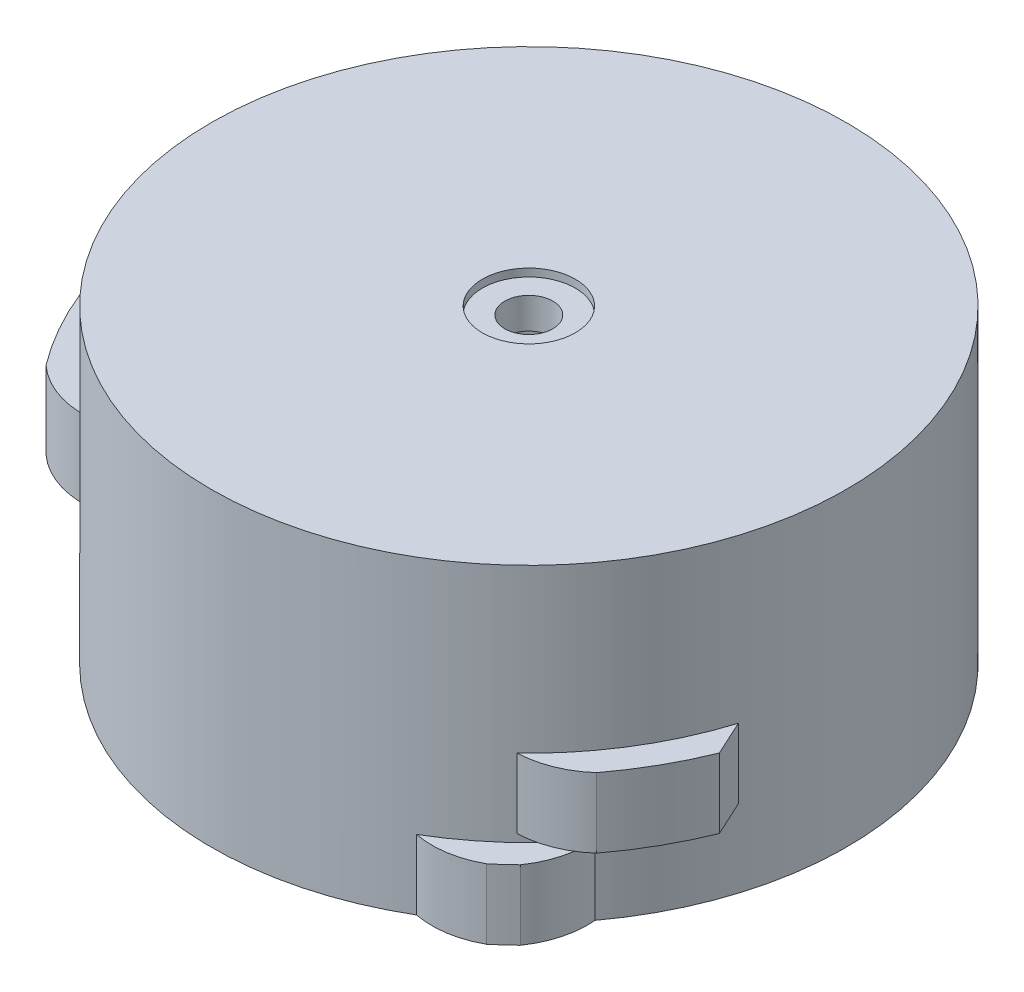
from build123d import *

# Parameters (mm, degrees)
SKETCH2_R           = 41
BOSS_EXTRUDE1_DEPTH = 40
HOME_DEPTH          = 9
END_R_DEPTH         = 9
END_L_DEPTH         = 10
SKETCH8_R           = 35
CUT_EXTRUDE1_DEPTH  = 10
CUT_EXTRUDE3_DEPTH  = 25
CUT_EXTRUDE4_REACH  = 7
SKETCH11_R          = 3.1
SKETCH12_R          = 6
CUT_EXTRUDE5_DEPTH  = 1


with BuildPart() as part:
    # Sketch2 → Boss-Extrude1 (new body)
    with BuildSketch(Plane(origin=(0, 0, 0), x_dir=(1, 0, 0), z_dir=(0, 1, 0))):
        Circle(SKETCH2_R)
    extrude(amount=BOSS_EXTRUDE1_DEPTH)

    # Sketch3 → Home (add)
    with BuildSketch(Plane(origin=(0, 0, 0), x_dir=(1, 0, 0), z_dir=(0, 1, 0))):
        with BuildLine():
            ThreePointArc((28.604048631, -34.088977719), (29.776311983, -33.069944734), (30.912297485, -32.010621115))
            ThreePointArc((30.912297485, -32.010621115), (32.604689255, -28.381998607), (32.953955321, -24.393376738))
            ThreePointArc((32.953955321, -24.393376738), (27.434354861, -30.468937845), (20.815120959, -35.323232291))
            ThreePointArc((20.815120959, -35.323232291), (24.818400986, -35.392804054), (28.604048631, -34.088977719))
        make_face()
    extrude(amount=HOME_DEPTH)

    # Sketch4 → End R (add)
    with BuildSketch(Plane(origin=(0, 10, 0), x_dir=(1, 0, 0), z_dir=(0, 1, 0))):
        with BuildLine():
            Line((41.259681528, -16.669993407), (39.164522306, -12.130135718))
            ThreePointArc((39.164522306, -12.130135718), (34.826898772, -21.635321166), (28.227629104, -29.735516729))
            ThreePointArc((28.227629104, -29.735516729), (32.143955565, -28.90276331), (35.539280197, -26.78076853))
            ThreePointArc((35.539280197, -26.78076853), (38.730828469, -21.912848425), (41.259681528, -16.669993407))
        make_face()
    extrude(amount=END_R_DEPTH)

    # Sketch6 → End L (add)
    with BuildSketch(Plane(origin=(0, 19, 0), x_dir=(1, 0, 0), z_dir=(0, 1, 0))):
        with BuildLine():
            Line((-41.259681528, -16.669993407), (-39.304086987, -11.669993407))
            ThreePointArc((-39.304086987, -11.669993407), (-34.902749486, -21.512742231), (-28.087672455, -29.867752779))
            ThreePointArc((-28.087672455, -29.867752779), (-32.085635632, -28.981220402), (-35.539280197, -26.78076853))
            ThreePointArc((-35.539280197, -26.78076853), (-38.730828469, -21.912848425), (-41.259681528, -16.669993407))
        make_face()
    extrude(amount=END_L_DEPTH)

    # Sketch8 → Cut-Extrude1 (cut)
    with BuildSketch(Plane.XZ):
        Circle(SKETCH8_R)
    extrude(amount=-CUT_EXTRUDE1_DEPTH, mode=Mode.SUBTRACT)

    # Sketch10 → Cut-Extrude3 (cut)
    with BuildSketch(Plane.XZ.offset(-10)):
        with BuildLine():
            Line((-2.5, -8.259618977), (2.5, -8.259618977))
            ThreePointArc((2.5, -8.259618977), (2.853553391, -8.406065586), (3, -8.759618977))
            Line((3, -8.759618977), (3, -10.842624221))
            ThreePointArc((3, -10.842624221), (0, 11.25), (-3, -10.842624221))
            Line((-3, -10.842624221), (-3, -8.759618977))
            ThreePointArc((-3, -8.759618977), (-2.853553391, -8.406065586), (-2.5, -8.259618977))
        make_face()
    extrude(amount=-CUT_EXTRUDE3_DEPTH, mode=Mode.SUBTRACT)

    # Sketch11 → Cut-Extrude4 (cut, up to next)
    with BuildSketch(Plane.XZ.offset(-35), mode=Mode.PRIVATE) as cut_extrude4_sk1:
        Circle(SKETCH11_R)
    cut_extrude4_tool1 = extrude(cut_extrude4_sk1.sketch, amount=-CUT_EXTRUDE4_REACH, mode=Mode.PRIVATE) & part.part
    add(cut_extrude4_tool1.solids().sort_by_distance((0, 35, 0))[0], mode=Mode.SUBTRACT)

    # Sketch12 → Cut-Extrude5 (cut)
    with BuildSketch(Plane(origin=(0, 40, 0), x_dir=(1, 0, 0), z_dir=(0, 1, 0))):
        Circle(SKETCH12_R)
    extrude(amount=-CUT_EXTRUDE5_DEPTH, mode=Mode.SUBTRACT)


solid = part.part
